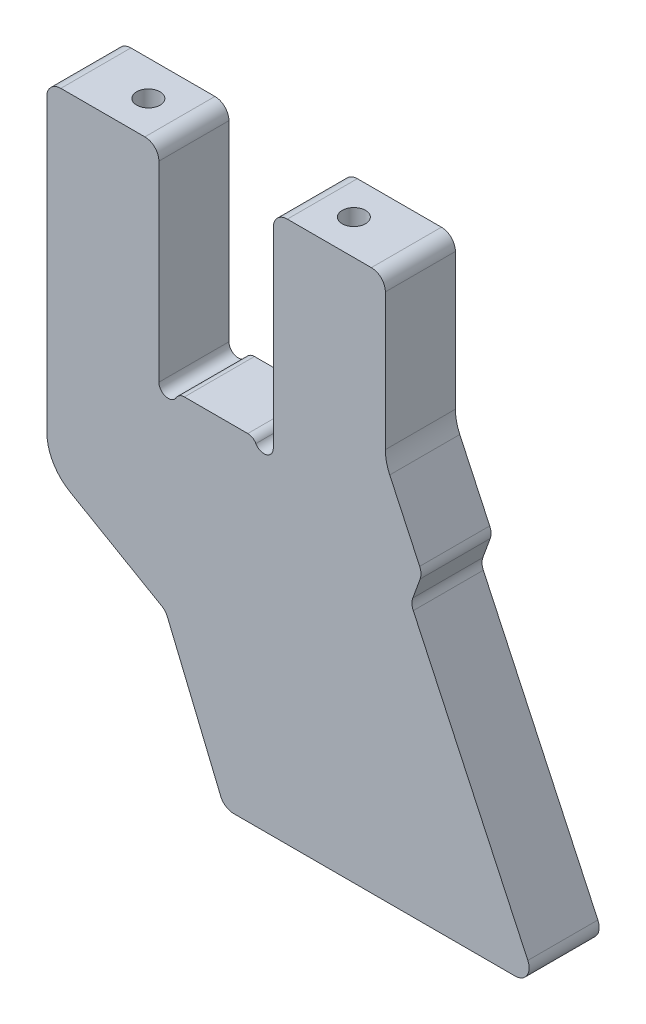
from build123d import *

# Parameters (mm, degrees)
BASE_EXTRUDE_DEPTH = 15
HOLE1_D            = 5
HOLE1_DEPTH        = 14
HOLE1_TIP          = 1.502151548


with BuildPart() as part:
    # Sketch1 → Base-Extrude (new body)
    with BuildSketch(Plane.XY):
        with BuildLine():
            Line((33.25, 44), (15.25, 44))
            ThreePointArc((15.25, 44), (13.128679656, 43.121320344), (12.25, 41))
            Line((12.25, 41), (12.25, 0))
            ThreePointArc((12.25, 0), (10.76763809, -1.931851653), (8.517949192, -1))
            ThreePointArc((8.517949192, -1), (7.785898385, -0.267949192), (6.785898385, 0))
            Line((6.785898385, 0), (-6.785898385, 0))
            ThreePointArc((-6.785898385, 0), (-7.785898385, -0.267949192), (-8.517949192, -1))
            ThreePointArc((-8.517949192, -1), (-10.76763809, -1.931851653), (-12.25, 0))
            Line((-12.25, 0), (-12.25, 41))
            ThreePointArc((-12.25, 41), (-13.128679656, 43.121320344), (-15.25, 44))
            Line((-15.25, 44), (-33.25, 44))
            ThreePointArc((-33.25, 44), (-35.371320344, 43.121320344), (-36.25, 41))
            Line((-36.25, 41), (-36.25, -21.226497308))
            ThreePointArc((-36.25, -21.226497308), (-34.910254038, -26.226497308), (-31.25, -29.886751346))
            Line((-31.25, -29.886751346), (-11.686313468, -41.181851032))
            ThreePointArc((-11.686313468, -41.181851032), (-10.930794046, -41.801889798), (-10.414674871, -42.631876946))
            Line((-10.414674871, -42.631876946), (0.982897316, -70.148050297))
            ThreePointArc((0.982897316, -70.148050297), (2.087825215, -71.494408837), (3.754535914, -72))
            Line((3.754535914, -72), (64.040943269, -72))
            ThreePointArc((64.040943269, -72), (66.571117606, -70.611898825), (66.75986663, -67.732145215))
            Line((66.75986663, -67.732145215), (42.229318474, -15.126214931))
            ThreePointArc((42.229318474, -15.126214931), (41.951097171, -13.989218308), (42.129163973, -12.832299716))
            Line((42.129163973, -12.832299716), (43.697595308, -8.52307004))
            ThreePointArc((43.697595308, -8.52307004), (43.87566211, -7.366151448), (43.597440806, -6.229154825))
            Line((43.597440806, -6.229154825), (37.18692213, 7.518246841))
            ThreePointArc((37.18692213, 7.518246841), (36.487039929, 9.580033319), (36.25, 11.744429459))
            Line((36.25, 11.744429459), (36.25, 41))
            ThreePointArc((36.25, 41), (35.371320344, 43.121320344), (33.25, 44))
        make_face()
    extrude(amount=-BASE_EXTRUDE_DEPTH)

    # Hole1
    with Locations(Plane(origin=(0, 44, 0), x_dir=(-1, 0, 0), z_dir=(0, 1, 0))):
        with Locations((22, -7.5), (-22, -7.5)):
            Hole(HOLE1_D / 2, depth=HOLE1_DEPTH)
            with Locations((0, 0, -(HOLE1_DEPTH + HOLE1_TIP / 2))):  # 118° drill point
                Cone(0, HOLE1_D / 2, HOLE1_TIP, mode=Mode.SUBTRACT)


solid = part.part
